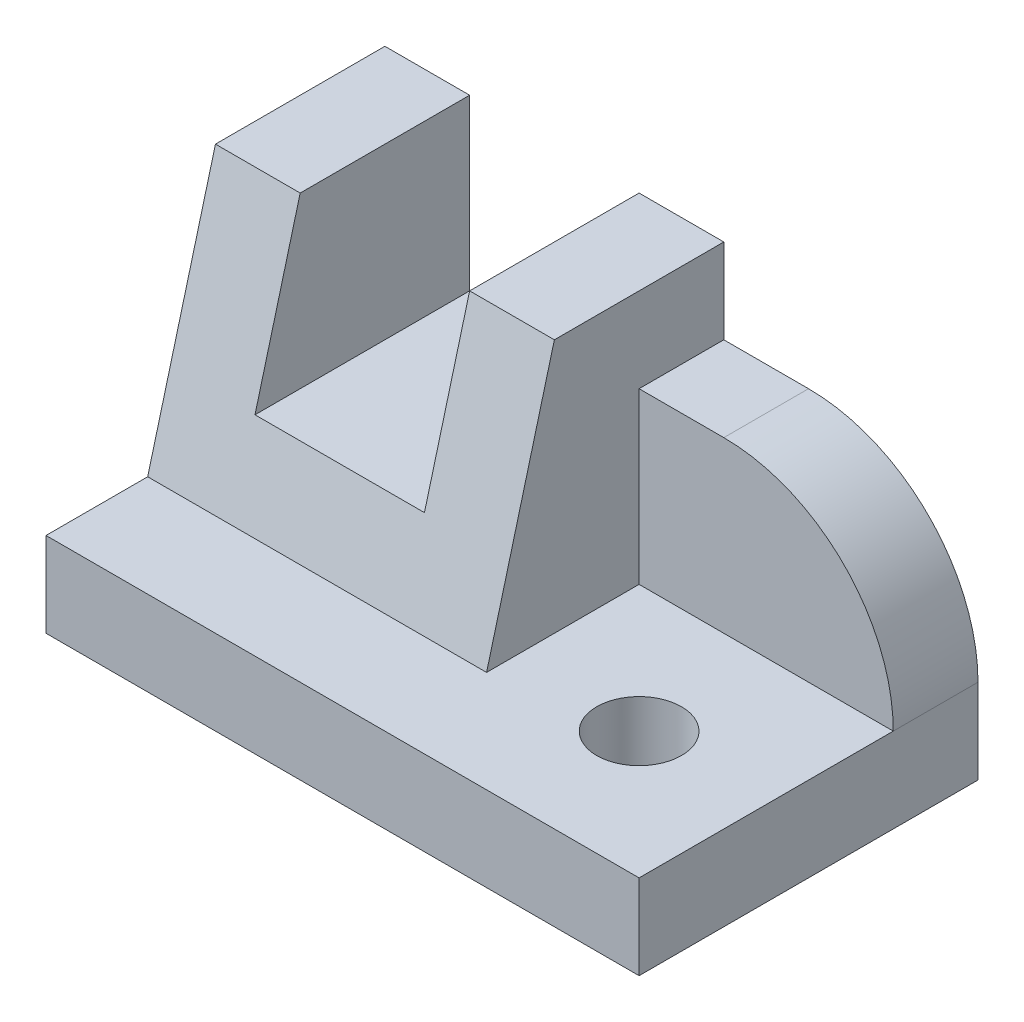
from build123d import *

# Parameters (mm, degrees)
BOSS_EXTRUDE1_DEPTH            = 40
SKETCH2_W                      = 40
SKETCH2_H                      = 30
BOSS_EXTRUDE2_DEPTH            = 20
BOSS_EXTRUDE3_DEPTH            = 30
CUT_EXTRUDE1_DEPTH             = 30
SKETCH5_W                      = 70
SKETCH5_H                      = 40
BOSS_EXTRUDE4_DEPTH            = 10
SKETCH6_W                      = 20
SKETCH6_H                      = 20
CUT_EXTRUDE2_DEPTH             = 41
F_10_0_10_DIAMETER_HOLE1_D     = 10
F_10_0_10_DIAMETER_HOLE1_DEPTH = 40
FILLET1_R                      = 20


with BuildPart() as part:
    # Sketch1 → Boss-Extrude1 (new body)
    with BuildSketch(Plane(origin=(0, 0, 0), x_dir=(0, -1, 0), z_dir=(-1, 0, 0))):
        Polygon((-10, -12), (-40, -20), (-10, -20), align=None)
    extrude(amount=-BOSS_EXTRUDE1_DEPTH)

    # Sketch2 → Boss-Extrude2 (add)
    with BuildSketch(Plane(origin=(0, 0, -20), x_dir=(-1, 0, 0), z_dir=(0, 0, -1))):
        with Locations((-20, 25)):
            Rectangle(SKETCH2_W, SKETCH2_H)
    extrude(amount=BOSS_EXTRUDE2_DEPTH)

    # Sketch3 → Boss-Extrude3 (add)
    with BuildSketch(Plane(origin=(40, 0, 0), x_dir=(0, 0, -1), z_dir=(1, 0, 0))):
        Polygon((40, 10), (0, 10), (20, 40), (40, 40), align=None)
    extrude(amount=BOSS_EXTRUDE3_DEPTH)

    # Sketch4 → Cut-Extrude1 (cut)
    with BuildSketch(Plane(origin=(70, 0, 0), x_dir=(0, 0, -1), z_dir=(1, 0, 0))):
        Polygon((20, 40), (0, 10), (30, 10), (30, 30), (40, 30), (40, 40), align=None)
    extrude(amount=-CUT_EXTRUDE1_DEPTH, mode=Mode.SUBTRACT)

    # Sketch5 → Boss-Extrude4 (add)
    with BuildSketch(Plane.XZ.offset(-10)):
        with Locations((35, -20)):
            Rectangle(SKETCH5_W, SKETCH5_H)
    extrude(amount=BOSS_EXTRUDE4_DEPTH)

    # Sketch6 → Cut-Extrude2 (cut, through all)
    with BuildSketch(Plane(origin=(0, 0, -40), x_dir=(-1, 0, 0), z_dir=(0, 0, -1))):
        with Locations((-20, 30)):
            Rectangle(SKETCH6_W, SKETCH6_H)
    extrude(amount=-CUT_EXTRUDE2_DEPTH, mode=Mode.SUBTRACT)

    # Ø10.0 (10) Diameter Hole1
    with Locations(Plane(origin=(0, 0, 0), x_dir=(-1, 0, 0), z_dir=(0, -1, 0))):
        with Locations((-55, 15)):
            Hole(F_10_0_10_DIAMETER_HOLE1_D / 2, depth=F_10_0_10_DIAMETER_HOLE1_DEPTH)

    # Fillet1
    fillet1_edges = [part.edges().sort_by_distance(p)[0] for p in [
        (70, 30, -35),
    ]]
    fillet(fillet1_edges, radius=FILLET1_R)


solid = part.part
